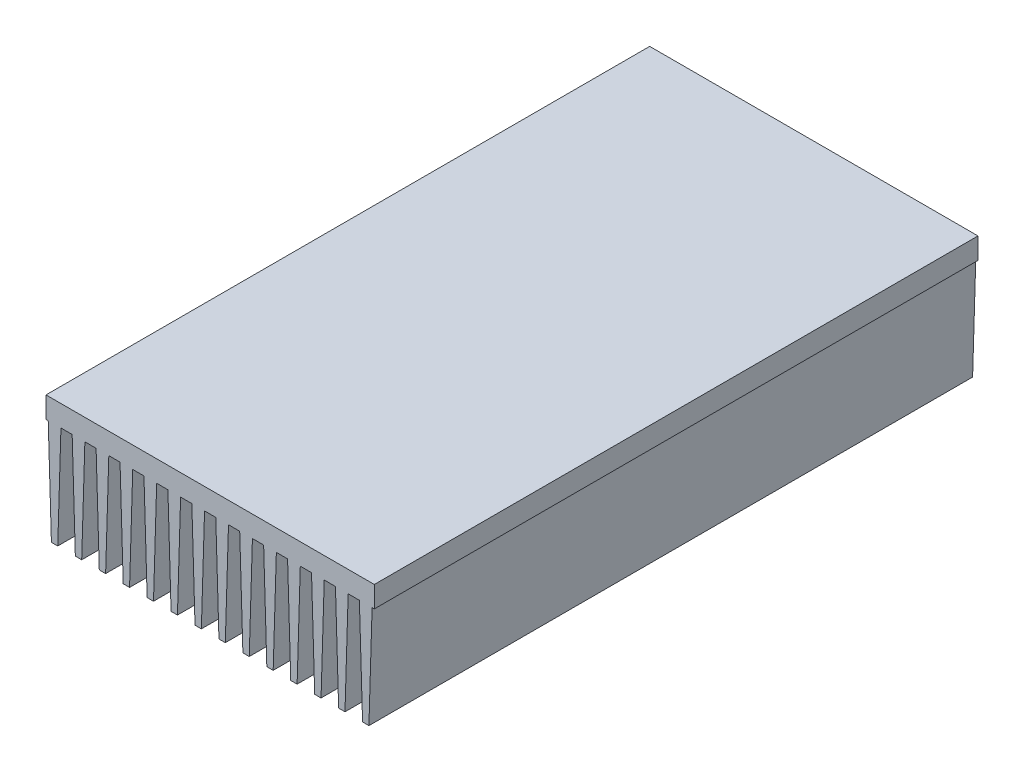
from build123d import *

# Parameters (mm, degrees)
RESSALTO_EXTRUS_O1_DEPTH = 285


with BuildPart() as part:
    # Esboço1 → Ressalto-extrusão1 (new body)
    with BuildSketch(Plane.XY):
        Polygon((0, 59), (155, 59), (155, 49), (153.95, 49), (152.45, 0), (149.45, 0), (147.95, 49), (142.65, 49), (141.15, 0), (138.15, 0), (136.65, 49), (131.35, 49), (129.85, 0), (126.85, 0), (125.35, 49), (120.05, 49), (118.55, 0), (115.55, 0), (114.05, 49), (108.75, 49), (107.25, 0), (104.25, 0), (102.75, 49), (97.45, 49), (95.95, 0), (92.95, 0), (91.45, 49), (86.15, 49), (84.65, 0), (81.65, 0), (80.15, 49), (74.85, 49), (73.35, 0), (70.35, 0), (68.85, 49), (63.55, 49), (62.05, 0), (59.05, 0), (57.55, 49), (52.25, 49), (50.75, 0), (47.75, 0), (46.25, 49), (40.95, 49), (39.45, 0), (36.45, 0), (34.95, 49), (29.65, 49), (28.15, 0), (25.15, 0), (23.65, 49), (18.35, 49), (16.85, 0), (13.85, 0), (12.35, 49), (7.05, 49), (5.55, 0), (2.55, 0), (1.05, 49), (0, 49), align=None)
    extrude(amount=RESSALTO_EXTRUS_O1_DEPTH)


solid = part.part
